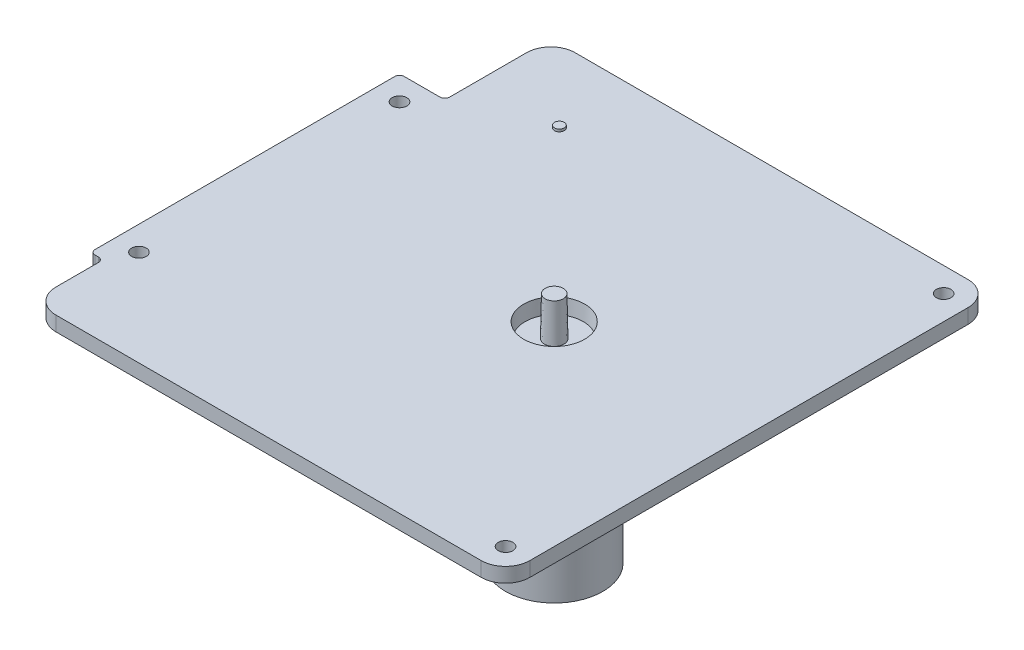
from build123d import *

# Parameters (mm, degrees)
BOSS_EXTRUDE1_DEPTH = 3
FILLET3_R           = 5
FILLET2_R           = 1
SKETCH2_R           = 1.5
CUT_EXTRUDE1_DEPTH  = 3
SKETCH5_R           = 10
BOSS_EXTRUDE2_DEPTH = 40
SKETCH3_R           = 6
CUT_EXTRUDE3_DEPTH  = 3
CUT_EXTRUDE3_TAPER  = -5
SKETCH6_R           = 2
BOSS_EXTRUDE3_DEPTH = 8
BOSS_EXTRUDE3_TAPER = 1
SKETCH7_R           = 1
BOSS_EXTRUDE4_DEPTH = 0.5


with BuildPart() as part:
    # Sketch1 → Boss-Extrude1 (new body)
    with BuildSketch(Plane(origin=(0, 23, 0), x_dir=(1, 0, 0), z_dir=(0, 1, 0))):
        Polygon((98.305417602, 50), (98.305417602, 28.219474586), (89, 28.219474586), (89, -35.308001182), (91.659783805, -35.308001182), (91.659783805, -50), (97.650210801, -50), (189, -50), (189, 50), align=None)
    extrude(amount=BOSS_EXTRUDE1_DEPTH)

    # Fillet3
    fillet3_edges = [part.edges().sort_by_distance(p)[0] for p in [
        (189, 24.5, 50),
        (91.659783805, 24.5, 50),
        (98.305417602, 24.5, -50),
        (189, 24.5, -50),
    ]]
    fillet(fillet3_edges, radius=FILLET3_R)

    # Fillet2
    fillet2_edges = [part.edges().sort_by_distance(p)[0] for p in [
        (91.659783805, 24.5, 35.308001182),
        (89, 24.5, 35.308001182),
        (89, 24.5, -28.219474586),
        (98.305417602, 24.5, -28.219474586),
    ]]
    fillet(fillet2_edges, radius=FILLET2_R)

    # Sketch2 → Cut-Extrude1 (cut)
    with BuildSketch(Plane(origin=(0, 23, 0), x_dir=(1, 0, 0), z_dir=(0, 1, 0))):
        with Locations((184, -45)):
            Circle(SKETCH2_R)
        with Locations((94, -30.308001182)):
            Circle(SKETCH2_R)
        with Locations((94, 23.219474586)):
            Circle(SKETCH2_R)
        with Locations((184, 45)):
            Circle(SKETCH2_R)
    extrude(amount=CUT_EXTRUDE1_DEPTH, mode=Mode.SUBTRACT)

    # Sketch5 → Boss-Extrude2 (add)
    with BuildSketch(Plane(origin=(0, 23, 0), x_dir=(1, 0, 0), z_dir=(0, 1, 0))):
        with Locations((149, 0)):
            Circle(SKETCH5_R)
    extrude(amount=-BOSS_EXTRUDE2_DEPTH)

    # Sketch3 → Cut-Extrude3 (cut)
    with BuildSketch(Plane(origin=(0, 23, 0), x_dir=(1, 0, 0), z_dir=(0, 1, 0))):
        with Locations((149, 0)):
            Circle(SKETCH3_R)
    extrude(amount=CUT_EXTRUDE3_DEPTH, taper=CUT_EXTRUDE3_TAPER, mode=Mode.SUBTRACT)

    # Sketch6 → Boss-Extrude3 (add)
    with BuildSketch(Plane(origin=(0, 23, 0), x_dir=(1, 0, 0), z_dir=(0, 1, 0))):
        with Locations((149, 0)):
            Circle(SKETCH6_R)
    extrude(amount=BOSS_EXTRUDE3_DEPTH, taper=BOSS_EXTRUDE3_TAPER)

    # Sketch7 → Boss-Extrude4 (add)
    with BuildSketch(Plane(origin=(0, 26, 0), x_dir=(1, 0, 0), z_dir=(0, 1, 0))):
        with Locations((115.065320099, 35)):
            Circle(SKETCH7_R)
    extrude(amount=BOSS_EXTRUDE4_DEPTH)


solid = part.part
